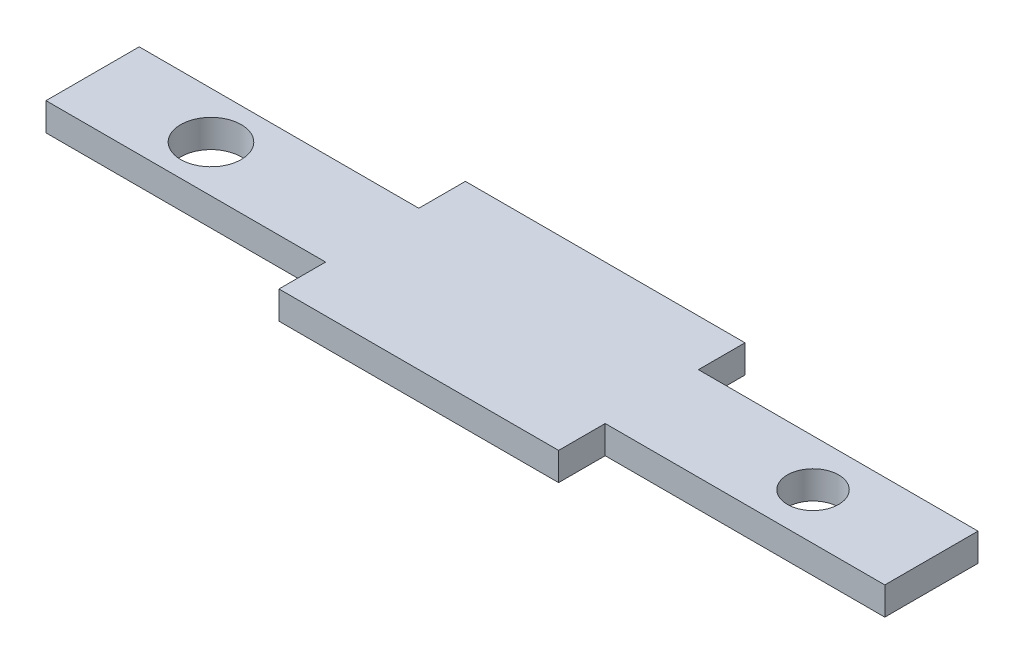
from build123d import *

# Parameters (mm, degrees)
SKETCH1_R           = 3.25
SKETCH1_R_2         = 2.75
BOSS_EXTRUDE1_DEPTH = 3


with BuildPart() as part:
    # Sketch1 → Boss-Extrude1 (new body)
    with BuildSketch(Plane(origin=(0, 0, 0), x_dir=(1, 0, 0), z_dir=(0, 1, 0))):
        Polygon((-32.478065847, 0), (-32.478065847, 10), (-2.478065847, 10), (-2.478065847, 15), (27.521934153, 15), (27.521934153, 10), (57.521934153, 10), (57.521934153, 0), (27.521934153, 0), (27.521934153, -5), (-2.478065847, -5), (-2.478065847, 0), align=None)
        with Locations((-19.778065847, 5)):
            Circle(SKETCH1_R, mode=Mode.SUBTRACT)
        with Locations((44.821934153, 5)):
            Circle(SKETCH1_R_2, mode=Mode.SUBTRACT)
    extrude(amount=BOSS_EXTRUDE1_DEPTH)


solid = part.part
